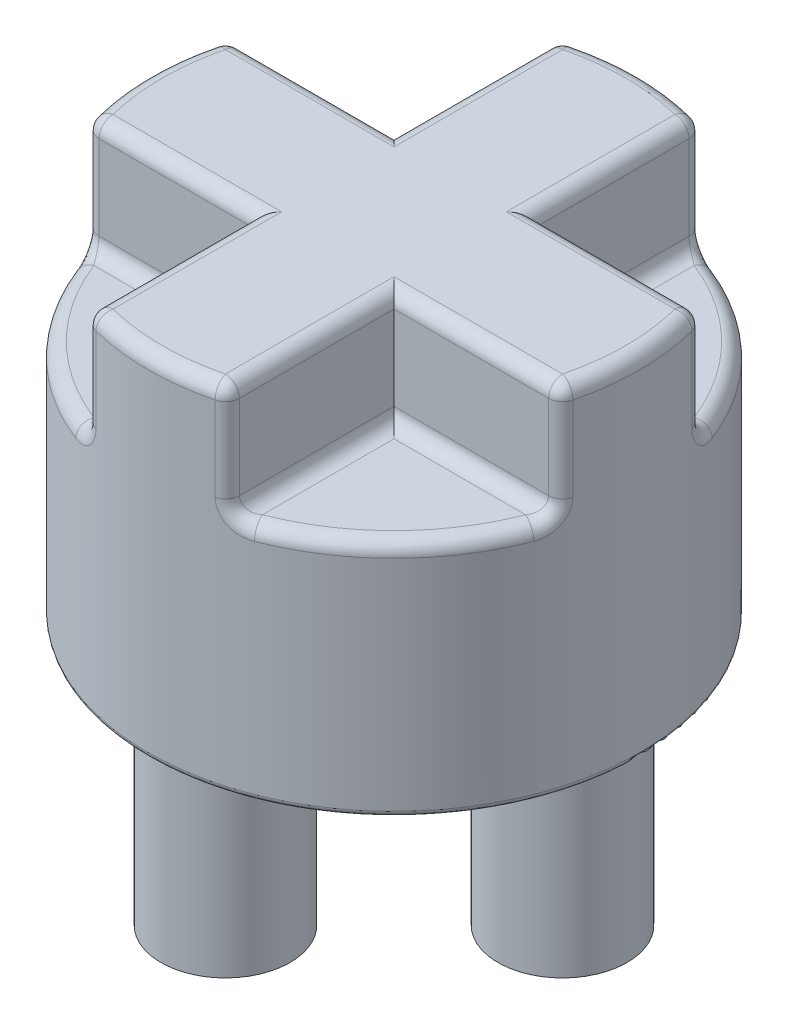
from build123d import *

# Parameters (mm, degrees)
SKETCH1_R           = 11.1125
BOSS_EXTRUDE1_DEPTH = 24.13
SKETCH7_R           = 1.905
CUT_EXTRUDE8_DEPTH  = 8.255
SKETCH8_R           = 13.133794805
SKETCH8_R_2         = 2.921
CUT_EXTRUDE9_DEPTH  = 8.255
FILLET9_R           = 0.254
SKETCH9_W           = 9.753722739
SKETCH9_H           = 9.436129392
SKETCH9_W_2         = 8.394478745
SKETCH9_H_2         = 8.574206565
SKETCH9_W_3         = 9.344219041
SKETCH9_H_3         = 9.681223662
SKETCH9_W_4         = 9.447354901
SKETCH9_H_4         = 10.110138634
CUT_EXTRUDE10_DEPTH = 5.08
FILLET10_R          = 0.635


with BuildPart() as part:
    # Sketch1 → Boss-Extrude1 (new body)
    with BuildSketch(Plane(origin=(0, 0, 0), x_dir=(1, 0, 0), z_dir=(0, 1, 0))):
        Circle(SKETCH1_R)
    extrude(amount=BOSS_EXTRUDE1_DEPTH)

    # Sketch7 → Cut-Extrude8 (cut)
    with BuildSketch(Plane.XZ):
        with Locations((0, 7.62)):
            Circle(SKETCH7_R)
        with Locations((7.62, 0)):
            Circle(SKETCH7_R)
        with Locations((0, -7.62)):
            Circle(SKETCH7_R)
        with Locations((-7.62, 0)):
            Circle(SKETCH7_R)
    extrude(amount=-CUT_EXTRUDE8_DEPTH, mode=Mode.SUBTRACT)

    # Sketch8 → Cut-Extrude9 (cut)
    with BuildSketch(Plane.XZ):
        Circle(SKETCH8_R)
        with Locations((-7.62, 0)):
            Circle(SKETCH8_R_2, mode=Mode.SUBTRACT)
        with Locations((0, 7.62)):
            Circle(SKETCH8_R_2, mode=Mode.SUBTRACT)
        with Locations((7.62, 0)):
            Circle(SKETCH8_R_2, mode=Mode.SUBTRACT)
        with Locations((0, -7.62)):
            Circle(SKETCH8_R_2, mode=Mode.SUBTRACT)
    extrude(amount=-CUT_EXTRUDE9_DEPTH, mode=Mode.SUBTRACT)

    # Fillet9
    fillet9_edges = [part.edges().sort_by_distance(p)[0] for p in [
        (-2.921, 8.255, 7.62),
        (4.699, 8.255, 0),
        (-2.921, 8.255, -7.62),
        (-10.541, 8.255, 0),
        (-11.1125, 8.255, 0),
    ]]
    fillet(fillet9_edges, radius=FILLET9_R)

    # Sketch9 → Cut-Extrude10 (cut)
    with BuildSketch(Plane(origin=(0, 24.13, 0), x_dir=(1, 0, 0), z_dir=(0, 1, 0))):
        with Locations((-8.05186137, 7.893064696)):
            Rectangle(SKETCH9_W, SKETCH9_H)
        with Locations((7.372239373, 7.462103283)):
            Rectangle(SKETCH9_W_2, SKETCH9_H_2)
        with Locations((7.847109521, -8.015611831)):
            Rectangle(SKETCH9_W_3, SKETCH9_H_3)
        with Locations((-7.898677451, -8.230069317)):
            Rectangle(SKETCH9_W_4, SKETCH9_H_4)
    extrude(amount=-CUT_EXTRUDE10_DEPTH, mode=Mode.SUBTRACT)

    # Fillet10
    fillet10_edges = [part.edges().sort_by_distance(p)[0] for p in [
        (10.996083637, 24.13, 1.604306982),
        (0, 24.13, -11.1125),
        (-11.1125, 24.13, 0),
        (0, 24.13, 11.1125),
        (-7.857724106, 19.05, -7.857724106),
        (-10.649273743, 21.59, -3.175),
        (-3.175, 21.59, -10.649273743),
        (7.857724106, 19.05, -7.857724106),
        (10.649273743, 21.59, -3.175),
        (3.175, 21.59, -10.649273743),
        (7.857724106, 19.05, 7.857724106),
        (10.649273743, 21.59, 3.175),
        (3.175, 21.59, 10.649273743),
        (-7.857724106, 19.05, 7.857724106),
        (-10.649273743, 21.59, 3.175),
        (-3.175, 21.59, 10.649273743),
        (-3.175, 19.05, 6.912136871),
        (-6.912136871, 19.05, 3.175),
        (-3.175, 24.13, 6.912136871),
        (-6.912136871, 24.13, 3.175),
        (3.175, 19.05, 6.912136871),
        (6.912136871, 19.05, 3.175),
        (3.175, 24.13, 6.912136871),
        (6.912136871, 24.13, 3.175),
        (3.175, 19.05, -6.912136871),
        (6.912136871, 19.05, -3.175),
        (3.175, 24.13, -6.912136871),
        (6.912136871, 24.13, -3.175),
        (-3.175, 19.05, -6.912136871),
        (-6.912136871, 19.05, -3.175),
        (-3.175, 24.13, -6.912136871),
        (-6.912136871, 24.13, -3.175),
    ]]
    fillet(fillet10_edges, radius=FILLET10_R)


solid = part.part
